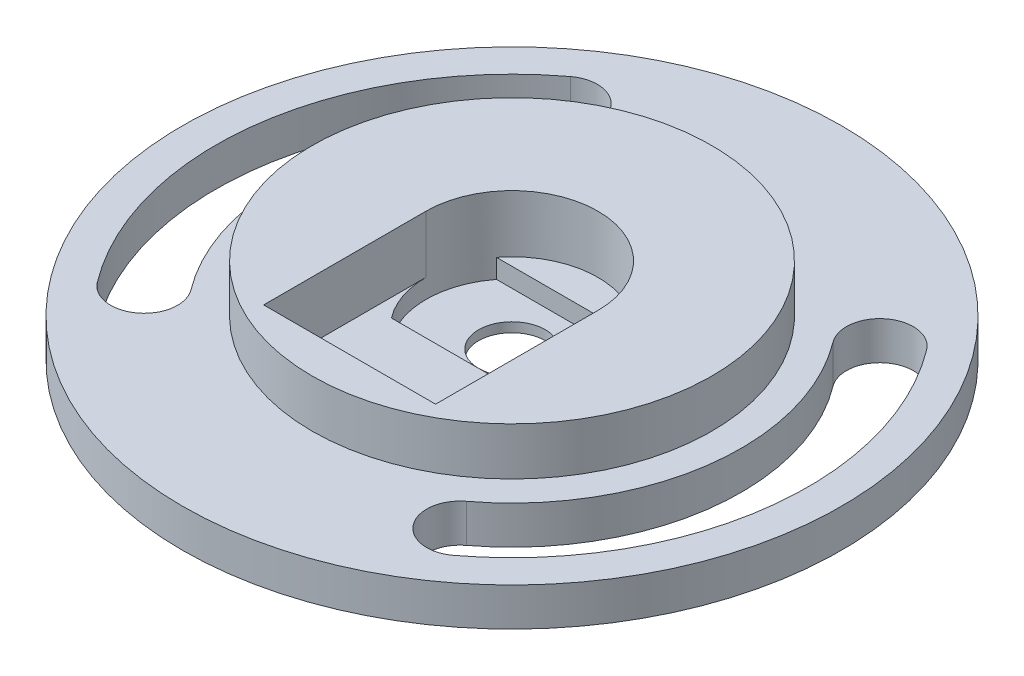
from build123d import *

# Parameters (mm, degrees)
SKETCH1_R               = 34.5
BOSS_EXTRUDE1_DEPTH     = 4
CUT_EXTRUDE1_DEPTH      = 1
CUT_EXTRUDE1_DEPTH_BACK = 5
SKETCH6_R               = 20.912013364
BOSS_EXTRUDE2_DEPTH     = 5
CUT_EXTRUDE3_DEPTH      = 6
SKETCH7_R               = 3.5
CUT_EXTRUDE4_DEPTH      = 1
CUT_EXTRUDE4_DEPTH_BACK = 10
CUT_EXTRUDE5_DEPTH      = 2
SKETCH9_W               = 2
SKETCH9_H               = 3
CUT_EXTRUDE6_DEPTH      = 10


with BuildPart() as part:
    # Sketch1 → Boss-Extrude1 (new body)
    with BuildSketch(Plane(origin=(0, 0, 0), x_dir=(1, 0, 0), z_dir=(0, 1, 0))):
        Circle(SKETCH1_R)
    extrude(amount=BOSS_EXTRUDE1_DEPTH)

    # Sketch2 → Cut-Extrude1 (cut, two sides)
    with BuildSketch(Plane(origin=(0, 4, 0), x_dir=(1, 0, 0), z_dir=(0, 1, 0))) as cut_extrude1_sk:
        with BuildLine():
            ThreePointArc((18.645465696, -24.765835519), (30.69642547, -4.327755005), (24.765835519, 18.645465696))
            ThreePointArc((24.765835519, 18.645465696), (19.864559575, 19.336475193), (19.173550079, 14.435199249))
            ThreePointArc((19.173550079, 14.435199249), (23.764974557, -3.350520004), (14.435199249, -19.173550079))
            ThreePointArc((14.435199249, -19.173550079), (13.744189753, -24.074826023), (18.645465696, -24.765835519))
        make_face()
        with BuildLine():
            ThreePointArc((-14.435199249, 19.173550079), (-23.764974557, 3.350520004), (-19.173550079, -14.435199249))
            ThreePointArc((-19.173550079, -14.435199249), (-19.864559575, -19.336475193), (-24.765835519, -18.645465696))
            ThreePointArc((-24.765835519, -18.645465696), (-30.69642547, 4.327755005), (-18.645465696, 24.765835519))
            ThreePointArc((-18.645465696, 24.765835519), (-13.744189753, 24.074826023), (-14.435199249, 19.173550079))
        make_face()
    extrude(amount=CUT_EXTRUDE1_DEPTH, mode=Mode.SUBTRACT)
    extrude(cut_extrude1_sk.sketch, amount=-CUT_EXTRUDE1_DEPTH_BACK, mode=Mode.SUBTRACT)

    # Sketch6 → Boss-Extrude2 (add)
    with BuildSketch(Plane(origin=(0, 4, 0), x_dir=(1, 0, 0), z_dir=(0, 1, 0))):
        Circle(SKETCH6_R)
    extrude(amount=BOSS_EXTRUDE2_DEPTH)

    # Sketch5 → Cut-Extrude3 (cut)
    with BuildSketch(Plane(origin=(0, 9, 0), x_dir=(1, 0, 0), z_dir=(0, 1, 0))):
        with BuildLine():
            Line((-9, 0), (-9, -17))
            Line((-9, -17), (9, -17))
            Line((9, -17), (9, 0))
            ThreePointArc((9, 0), (0, 9), (-9, 0))
        make_face()
    extrude(amount=-CUT_EXTRUDE3_DEPTH, mode=Mode.SUBTRACT)

    # Sketch7 → Cut-Extrude4 (cut, two sides)
    with BuildSketch(Plane(origin=(0, 9, 0), x_dir=(1, 0, 0), z_dir=(0, 1, 0))) as cut_extrude4_sk:
        Circle(SKETCH7_R)
    extrude(amount=CUT_EXTRUDE4_DEPTH, mode=Mode.SUBTRACT)
    extrude(cut_extrude4_sk.sketch, amount=-CUT_EXTRUDE4_DEPTH_BACK, mode=Mode.SUBTRACT)

    # Sketch8 → Cut-Extrude5 (cut)
    with BuildSketch(Plane(origin=(0, 3, 0), x_dir=(1, 0, 0), z_dir=(0, 1, 0))):
        with BuildLine():
            Line((7.123903424, -5.5), (-7.123903424, -5.5))
            ThreePointArc((-7.123903424, -5.5), (-9, 0), (-7.123903424, 5.5))
            Line((-7.123903424, 5.5), (7.123903424, 5.5))
            ThreePointArc((7.123903424, 5.5), (9, 0), (7.123903424, -5.5))
        make_face()
    extrude(amount=-CUT_EXTRUDE5_DEPTH, mode=Mode.SUBTRACT)

    # Sketch9 → Cut-Extrude6 (cut, through all)
    with BuildSketch(Plane(origin=(0, 9, 0), x_dir=(1, 0, 0), z_dir=(0, 1, 0))):
        with Locations((7.763148871, 0.138067302)):
            Rectangle(SKETCH9_W, SKETCH9_H)
    extrude(amount=-CUT_EXTRUDE6_DEPTH, mode=Mode.SUBTRACT)


solid = part.part
